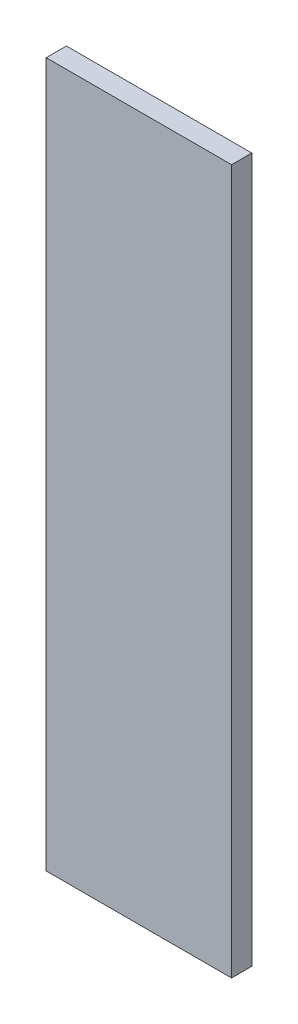
from build123d import *

# Parameters (mm, degrees)
SKETCH1_W           = 165
SKETCH1_H           = 627
BOSS_EXTRUDE1_DEPTH = 18


with BuildPart() as part:
    # Sketch1 → Boss-Extrude1 (new body)
    with BuildSketch(Plane.XY):
        Rectangle(SKETCH1_W, SKETCH1_H)
    extrude(amount=BOSS_EXTRUDE1_DEPTH)


solid = part.part
